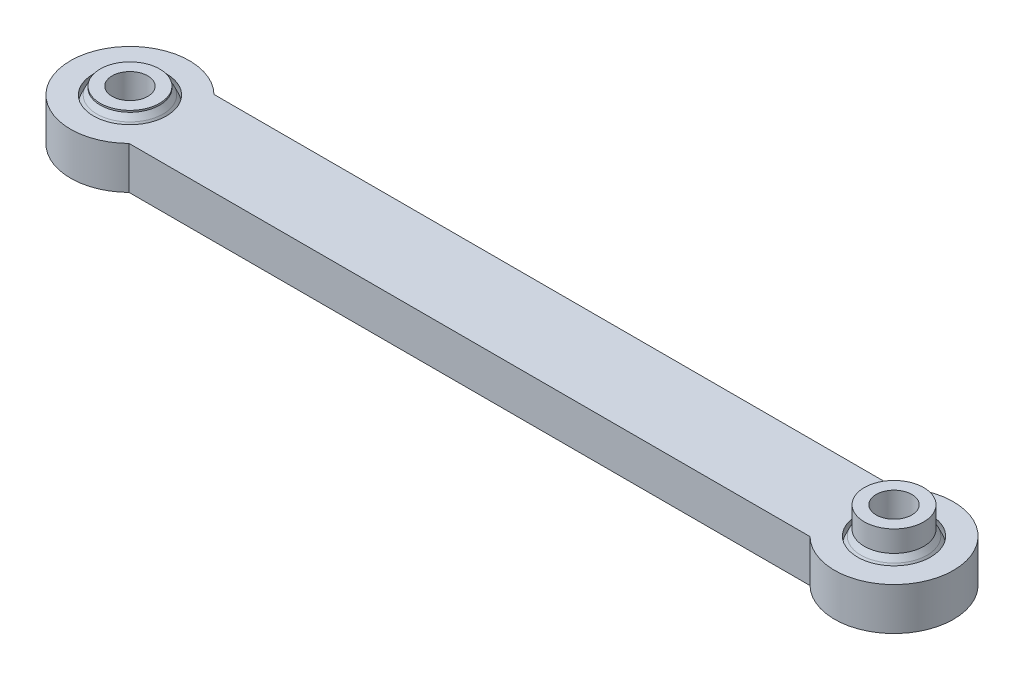
from build123d import *

# Parameters (mm, degrees)
BOSS_EXTRUDE1_DEPTH = 5
SKETCH7_R           = 2.1
CUT_EXTRUDE1_DEPTH  = 11
SKETCH8_R           = 3.5
SKETCH8_R_2         = 2.1
BOSS_EXTRUDE2_DEPTH = 2.5
SKETCH9_R           = 5.053778945
CUT_EXTRUDE2_DEPTH  = 2
SKETCH10_R          = 7.844630339
CUT_EXTRUDE3_DEPTH  = 0.3


with BuildPart() as part:
    # Sketch1 → Revolve1 (revolve)
    with BuildSketch(Plane.XY):
        with BuildLine():
            Line((-52, 2.5), (-52, -2.5))
            Line((-52, -2.5), (-49.3, -2.5))
            ThreePointArc((-49.3, -2.5), (-49.973932046, 0), (-49.3, 2.5))
            Line((-49.3, 2.5), (-52, 2.5))
        make_face()
    revolve(axis=Axis((-45, -2.5, 0), (0, 1, 0)))



with BuildPart() as body_2:
    # Sketch2 → Revolve2 (revolve)
    with BuildSketch(Plane.XY):
        with BuildLine():
            Line((52, 2.5), (52, -2.5))
            Line((52, -2.5), (49.3, -2.5))
            ThreePointArc((49.3, -2.5), (49.973932046, 0), (49.3, 2.5))
            Line((49.3, 2.5), (52, 2.5))
        make_face()
    revolve(axis=Axis((45, -2.5, 0), (0, 1, 0)))


with BuildPart() as part_1:
    add(part.part)

    add(body_2.part)  # Boss-Extrude1 merges body 2
    # Sketch4 → Boss-Extrude1 (add)
    with BuildSketch(Plane(origin=(0, 2.5, 0), x_dir=(1, 0, 0), z_dir=(0, 1, 0))):
        with BuildLine():
            Line((-40.101020514, 5), (-40.101020514, 3.464101615))
            ThreePointArc((-40.101020514, 3.464101615), (-39, 0), (-40.101020514, -3.464101615))
            Line((-40.101020514, -3.464101615), (-40.101020514, -5))
            Line((-40.101020514, -5), (40.101020514, -5))
            Line((40.101020514, -5), (40.101020514, -3.464101615))
            ThreePointArc((40.101020514, -3.464101615), (39, 0), (40.101020514, 3.464101615))
            Line((40.101020514, 3.464101615), (40.101020514, 5))
            Line((40.101020514, 5), (-40.101020514, 5))
        make_face()
    extrude(amount=-BOSS_EXTRUDE1_DEPTH)


with BuildPart() as body_2_2:
    # Sketch5 → Revolve3 (revolve)
    with BuildSketch(Plane.XY):
        with BuildLine():
            ThreePointArc((-48.9, 2.5), (-48.490203099, 3.093468733), (-48.1, 3.7))
            Line((-48.1, 3.7), (-48.1, 5.7))
            Line((-48.1, 5.7), (-45, 5.7))
            Line((-45, 5.7), (-45, 3.7))
            Line((-45, 3.7), (-45, -2.5))
            Line((-45, -2.5), (-48.9, -2.5))
            ThreePointArc((-48.9, -2.5), (-49.382326119, -1.293758269), (-49.5, 0))
            ThreePointArc((-49.5, 0), (-49.382326119, 1.293758269), (-48.9, 2.5))
        make_face()
    revolve(axis=Axis((-45, -2.5, 0), (0, 1, 0)))


with BuildPart() as body_3:
    # Sketch6 → Revolve4 (revolve)
    with BuildSketch(Plane.XY):
        with BuildLine():
            ThreePointArc((48.1, 3.7), (48.490203099, 3.093468733), (48.9, 2.5))
            ThreePointArc((48.9, 2.5), (49.382326119, 1.293758269), (49.5, 0))
            ThreePointArc((49.5, 0), (49.382326119, -1.293758269), (48.9, -2.5))
            Line((48.9, -2.5), (45, -2.5))
            Line((45, -2.5), (45, 5.7))
            Line((45, 5.7), (48.1, 5.7))
            Line((48.1, 5.7), (48.1, 3.7))
        make_face()
    revolve(axis=Axis((45, 5.7, 0), (0, -1, 0)))


with BuildPart() as cut_extrude1_tool:
    # Sketch7 → Cut-Extrude1 (new body)
    with BuildSketch(Plane(origin=(0, 5.7, 0), x_dir=(1, 0, 0), z_dir=(0, 1, 0))):
        with Locations((-45, 0)):
            Circle(SKETCH7_R)
        with Locations((45, 0)):
            Circle(SKETCH7_R)
    extrude(amount=-CUT_EXTRUDE1_DEPTH)


with BuildPart() as body_2_2_1:
    add(body_2_2.part)

    # Cut-Extrude1: cut by cut_extrude1_tool
    add(cut_extrude1_tool.part, mode=Mode.SUBTRACT)



with BuildPart() as body_3_1:
    add(body_3.part)

    # Cut-Extrude1: cut by cut_extrude1_tool
    add(cut_extrude1_tool.part, mode=Mode.SUBTRACT)


with BuildPart() as body_2_2_2:
    add(body_2_2_1.part)

    add(body_3_1.part)  # Boss-Extrude2 merges body 3
    # Sketch8 → Boss-Extrude2 (add)
    with BuildSketch(Plane(origin=(0, 5.7, 0), x_dir=(1, 0, 0), z_dir=(0, 1, 0))):
        with Locations((-45, 0)):
            Circle(SKETCH8_R)
        with Locations((-45, 0)):
            Circle(SKETCH8_R_2, mode=Mode.SUBTRACT)
        with Locations((45, 0)):
            Circle(SKETCH8_R)
        with Locations((45, 0)):
            Circle(SKETCH8_R_2, mode=Mode.SUBTRACT)
    extrude(amount=-BOSS_EXTRUDE2_DEPTH)

    # Sketch9 → Cut-Extrude2 (cut)
    with BuildSketch(Plane(origin=(0, 5.7, 0), x_dir=(1, 0, 0), z_dir=(0, 1, 0))):
        with Locations((-45, 0)):
            Circle(SKETCH9_R)
    extrude(amount=-CUT_EXTRUDE2_DEPTH, mode=Mode.SUBTRACT)

    # Sketch10 → Cut-Extrude3 (cut)
    with BuildSketch(Plane(origin=(0, 3.7, 0), x_dir=(1, 0, 0), z_dir=(0, 1, 0))):
        with Locations((-45, 0)):
            Circle(SKETCH10_R)
    extrude(amount=-CUT_EXTRUDE3_DEPTH, mode=Mode.SUBTRACT)


solid = Compound([part_1.part, body_2_2_2.part])
